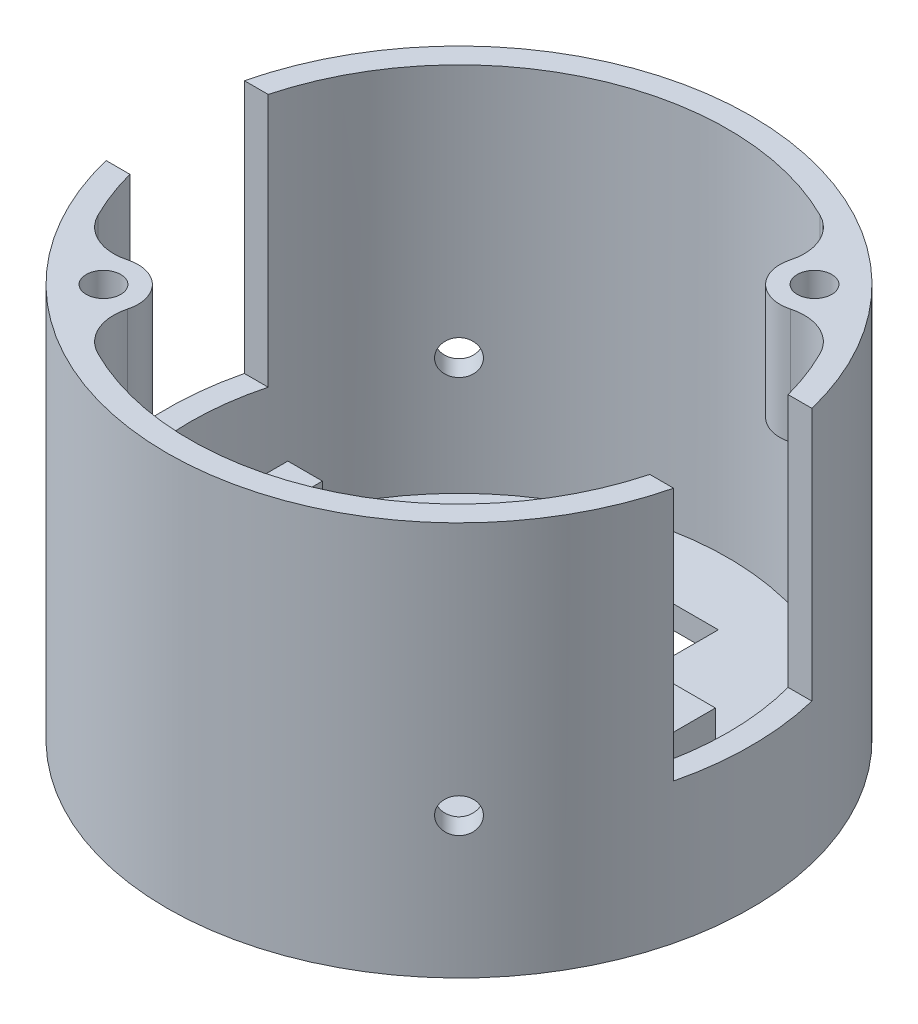
from build123d import *

# Parameters (mm, degrees)
SKETCH1_R           = 25.34
BOSS_EXTRUDE1_DEPTH = 34.2
SHELL1_T            = -2
SKETCH2_W           = 50.68
SKETCH2_H           = 12
CUT_EXTRUDE1_DEPTH  = 22
SKETCH3_W           = 5
SKETCH3_H           = 13
SKETCH3_W_2         = 3
BOSS_EXTRUDE2_DEPTH = 5
SKETCH4_R           = 3
SKETCH4_R_2         = 1.5
BOSS_EXTRUDE3_DEPTH = 10
FILLET1_R           = 4
SKETCH6_R           = 1.5
CUT_EXTRUDE2_DEPTH  = 71.08683178
SKETCH7_W           = 10
SKETCH7_H           = 5
CUT_EXTRUDE3_DEPTH  = 49.177496994


with BuildPart() as part:
    # Sketch1 → Boss-Extrude1 (new body)
    with BuildSketch(Plane(origin=(0, 0, 0), x_dir=(1, 0, 0), z_dir=(0, 1, 0))):
        with Locations(Location((0, 0, 0), (0, 0, 270))):
            Circle(SKETCH1_R)
    extrude(amount=BOSS_EXTRUDE1_DEPTH)

    # Shell1
    shell1_openings = [part.faces().sort_by_distance(p)[0] for p in [
        (0, 34.2, 0),
    ]]
    offset(amount=SHELL1_T, openings=shell1_openings, kind=Kind.INTERSECTION)

    # Sketch2 → Cut-Extrude1 (cut)
    with BuildSketch(Plane(origin=(0, 34.2, 0), x_dir=(1, 0, 0), z_dir=(0, 1, 0))):
        Rectangle(SKETCH2_W, SKETCH2_H)
    extrude(amount=-CUT_EXTRUDE1_DEPTH, mode=Mode.SUBTRACT)

    # Sketch3 → Boss-Extrude2 (add)
    with BuildSketch(Plane(origin=(0, 2, 0), x_dir=(1, 0, 0), z_dir=(0, 1, 0))):
        with Locations((13.25, 0)):
            Rectangle(SKETCH3_W, SKETCH3_H)
        with Locations((19.85, 0)):
            Rectangle(SKETCH3_W_2, SKETCH3_H)
        with Locations((-19.85, 0)):
            Rectangle(SKETCH3_W_2, SKETCH3_H)
        with Locations((-13.25, 0)):
            Rectangle(SKETCH3_W, SKETCH3_H)
    extrude(amount=BOSS_EXTRUDE2_DEPTH)

    # Sketch4 → Boss-Extrude3 (add)
    with BuildSketch(Plane(origin=(0, 34.2, 0), x_dir=(1, 0, 0), z_dir=(0, 1, 0))):
        with Locations((15.423138364, 15.423138364)):
            Circle(SKETCH4_R)
        with Locations(Location((15.423138364, 15.423138364, 0), (0, 0, 270))):
            Circle(SKETCH4_R_2, mode=Mode.SUBTRACT)
        with Locations((-15.423138364, -15.423138364)):
            Circle(SKETCH4_R)
        with Locations(Location((-15.423138364, -15.423138364, 0), (0, 0, 270))):
            Circle(SKETCH4_R_2, mode=Mode.SUBTRACT)
    extrude(amount=-BOSS_EXTRUDE3_DEPTH)

    # Fillet1
    fillet1_edges = [part.edges().sort_by_distance(p)[0] for p in [
        (-14.510692455, 29.2, 18.28101213),
        (-18.28101213, 29.2, 14.510692455),
        (14.510692455, 29.2, -18.28101213),
        (18.28101213, 29.2, -14.510692455),
    ]]
    fillet(fillet1_edges, radius=FILLET1_R)

    # Sketch6 → Cut-Extrude2 (cut, through all)
    with BuildSketch(Plane(origin=(17.918085835, 34.2, 17.918085835), x_dir=(0.7071067811865487, 0, -0.7071067811865464), z_dir=(0.7071067811865464, 0, 0.7071067811865487))):
        with Locations((0, -22)):
            Circle(SKETCH6_R)
    extrude(amount=-CUT_EXTRUDE2_DEPTH, mode=Mode.SUBTRACT)

    # Sketch7 → Cut-Extrude3 (cut, through all)
    with BuildSketch(Plane(origin=(0, 2, 0), x_dir=(1, 0, 0), z_dir=(0, 1, 0))):
        with Locations((0, 15)):
            Rectangle(SKETCH7_W, SKETCH7_H)
        with Locations((0, -15)):
            Rectangle(SKETCH7_W, SKETCH7_H)
    extrude(amount=-CUT_EXTRUDE3_DEPTH, mode=Mode.SUBTRACT)


solid = part.part
